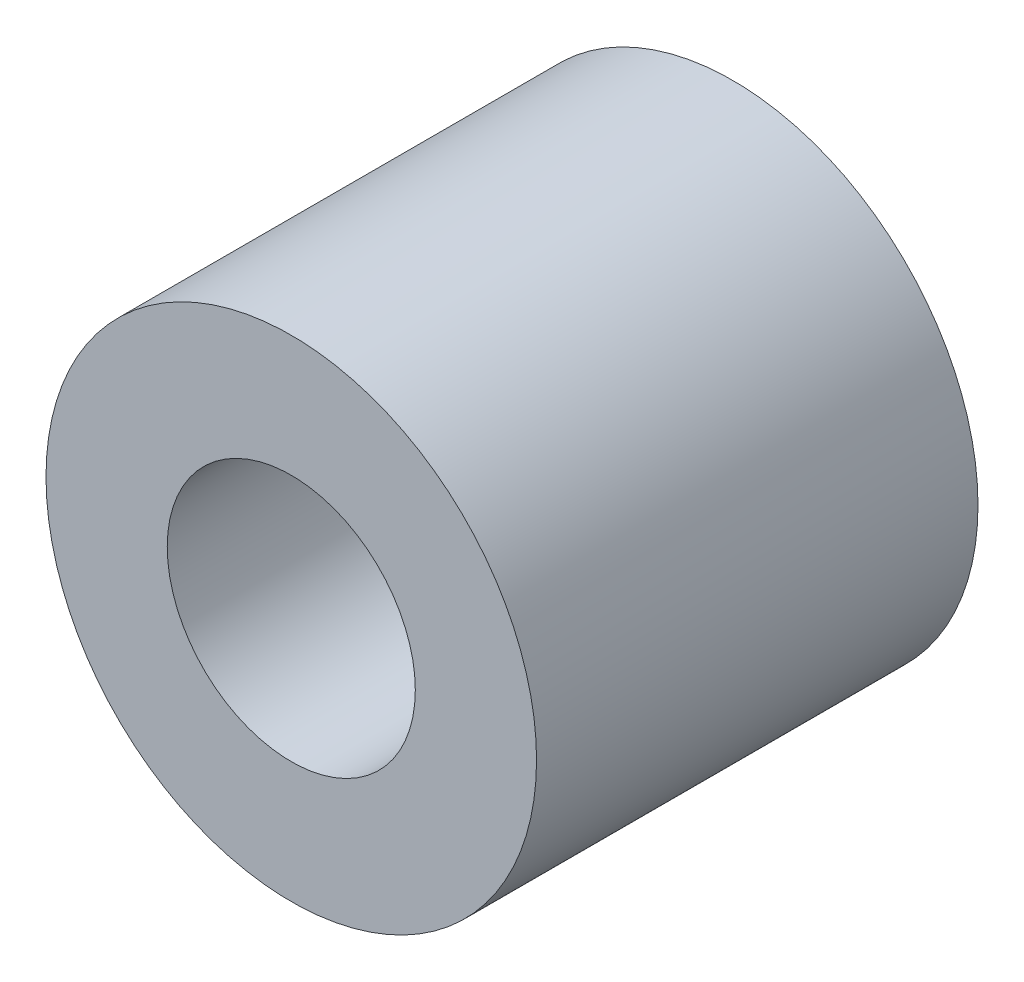
from build123d import *

# Parameters (mm, degrees)
SKETCH1_R             = 4.445
BOSS_EXTRUDE1_DEPTH   = 4
F_8_CLEARANCE_HOLE1_D = 4.4958


with BuildPart() as part:
    # Sketch1 → Boss-Extrude1 (new body, symmetric)
    with BuildSketch(Plane.XY):
        Circle(SKETCH1_R)
    extrude(amount=BOSS_EXTRUDE1_DEPTH, both=True)

    # #8 Clearance Hole1 (through all)
    with Locations(Plane.XY.offset(4)):
        with Locations((0, 0)):
            Hole(F_8_CLEARANCE_HOLE1_D / 2)


solid = part.part
